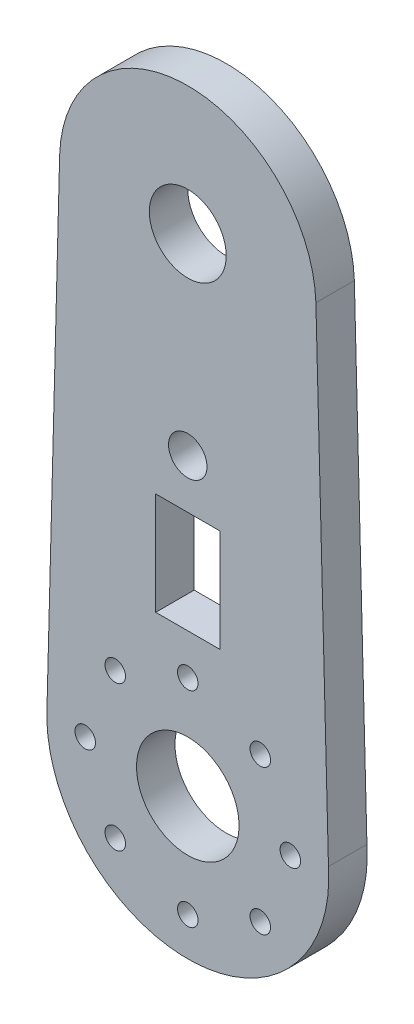
from build123d import *

# Parameters (mm, degrees)
IZIM1_R                     = 0.8
IZIM1_R_2                   = 3
IZIM1_R_3                   = 4
IZIM1_R_4                   = 1.5
IZIM1_W                     = 5
IZIM1_H                     = 8
Y_KSEKLIK_EKSTR_ZYON1_DEPTH = 3


with BuildPart() as part:
    # Çizim1 → Yükseklik-Ekstrüzyon1 (new body)
    with BuildSketch(Plane.XY.offset(3)):
        with BuildLine():
            Line((10.975849913, 0.728504421), (9.994509837, 38.331320273))
            ThreePointArc((9.994509837, 38.331320273), (0, 48), (-9.994509837, 38.331320273))
            Line((-9.994509837, 38.331320273), (-10.975849913, 0.728504421))
            ThreePointArc((-10.975849913, 0.728504421), (0, -11), (10.975849913, 0.728504421))
        make_face()
        with Locations((0, 8)):
            Circle(IZIM1_R, mode=Mode.SUBTRACT)
        with Locations((5.656854249, 5.656854249)):
            Circle(IZIM1_R, mode=Mode.SUBTRACT)
        with Locations((8, 0)):
            Circle(IZIM1_R, mode=Mode.SUBTRACT)
        with Locations((5.656854249, -5.656854249)):
            Circle(IZIM1_R, mode=Mode.SUBTRACT)
        with Locations((0, -8)):
            Circle(IZIM1_R, mode=Mode.SUBTRACT)
        with Locations((-5.656854249, -5.656854249)):
            Circle(IZIM1_R, mode=Mode.SUBTRACT)
        with Locations((-8, 0)):
            Circle(IZIM1_R, mode=Mode.SUBTRACT)
        with Locations((0, 38)):
            Circle(IZIM1_R_2, mode=Mode.SUBTRACT)
        Circle(IZIM1_R_3, mode=Mode.SUBTRACT)
        with Locations((0, 23)):
            Circle(IZIM1_R_4, mode=Mode.SUBTRACT)
        with Locations((-5.656854249, 5.656854249)):
            Circle(IZIM1_R, mode=Mode.SUBTRACT)
        with Locations((0, 15.169050412)):
            Rectangle(IZIM1_W, IZIM1_H, mode=Mode.SUBTRACT)
    extrude(amount=-Y_KSEKLIK_EKSTR_ZYON1_DEPTH)


solid = part.part
